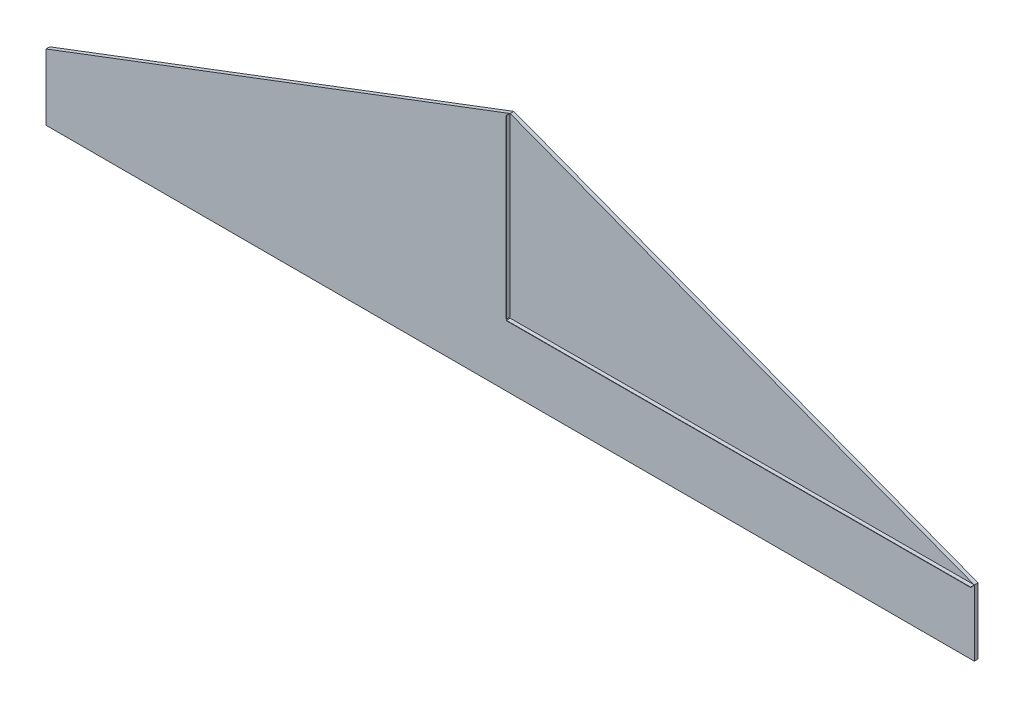
from build123d import *

# Parameters (mm, degrees)
SALIENTE_EXTRUIR1_DEPTH = 100
CROQUIS6_W              = 10
CROQUIS6_H              = 4744.143758361
EXTRUIR_L_MINA1_DEPTH   = 100


with BuildPart() as part:
    # Croquis5 → Saliente-Extruir1 (new body)
    with BuildSketch(Plane.XY):
        Polygon((12500, 0), (0, 4744.143758361), (-12500, 0), (-12500, -1780), (12500, -1780), align=None)
    extrude(amount=SALIENTE_EXTRUIR1_DEPTH)

    # Croquis6 → Extruir-Lámina1 (add)
    with BuildSketch(Plane.XY.offset(100)):
        with Locations((-5, 2372.071879181)):
            Rectangle(CROQUIS6_W, CROQUIS6_H)
        Polygon((0, -29.334752026), (12500, 0), (12500.023467737, -9.999972463), (0.023467737, -39.334724489), align=None)
    extrude(amount=EXTRUIR_L_MINA1_DEPTH)


solid = part.part
